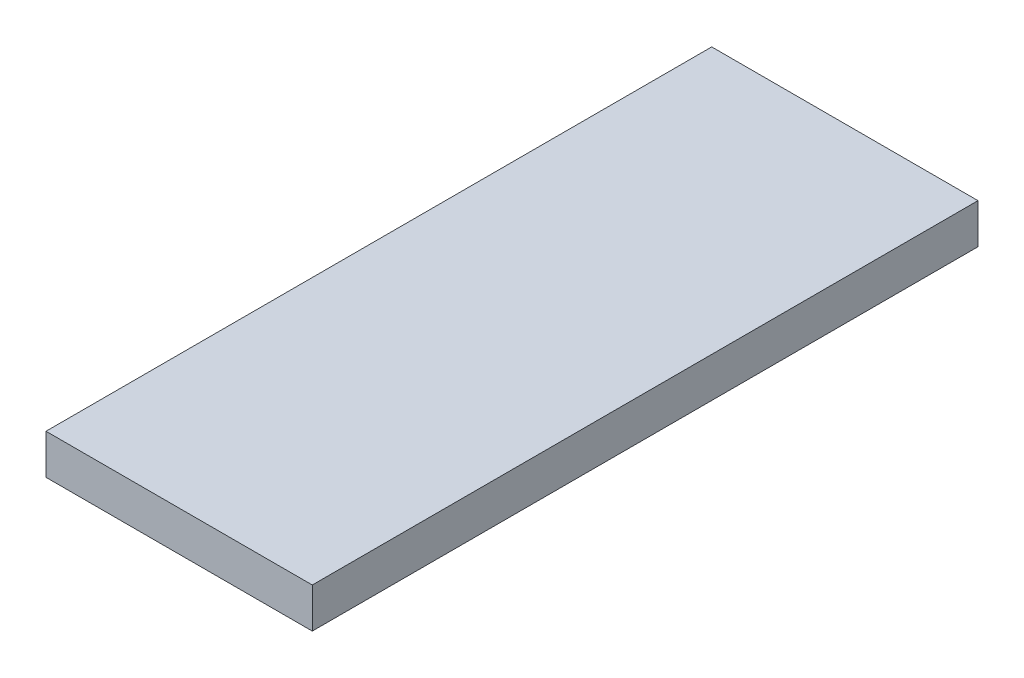
from build123d import *

# Parameters (mm, degrees)
SKETCH1_W           = 50.8
SKETCH1_H           = 127
BOSS_EXTRUDE1_DEPTH = 7.62


with BuildPart() as part:
    # Sketch1 → Boss-Extrude1 (new body)
    with BuildSketch(Plane(origin=(0, 0, 0), x_dir=(1, 0, 0), z_dir=(0, 1, 0))):
        with Locations((25.4, 63.5)):
            Rectangle(SKETCH1_W, SKETCH1_H)
    extrude(amount=BOSS_EXTRUDE1_DEPTH)


solid = part.part
